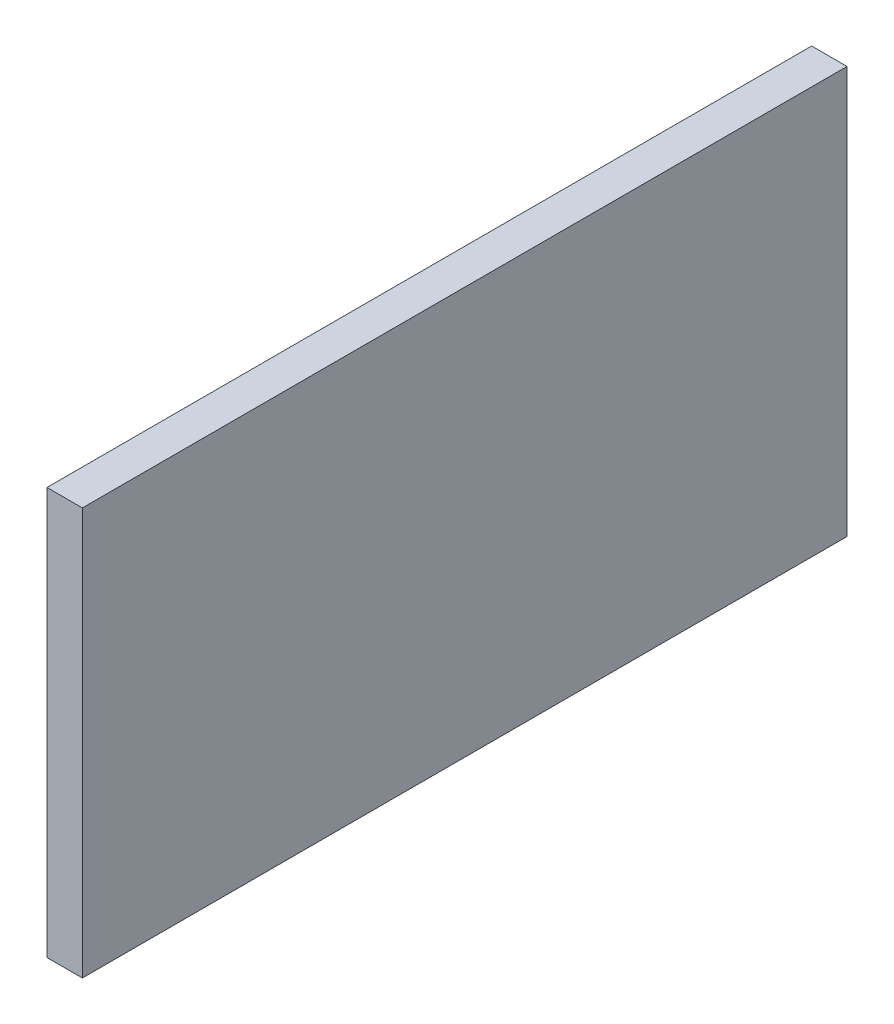
from build123d import *

# Parameters (mm, degrees)
SKETCH1_W           = 68.58
SKETCH1_H           = 36.5125
BOSS_EXTRUDE1_DEPTH = 3.175


with BuildPart() as part:
    # Sketch1 → Boss-Extrude1 (new body)
    with BuildSketch(Plane(origin=(0, 0, 0), x_dir=(0, 0, -1), z_dir=(1, 0, 0))):
        Rectangle(SKETCH1_W, SKETCH1_H)
    extrude(amount=BOSS_EXTRUDE1_DEPTH)


solid = part.part
